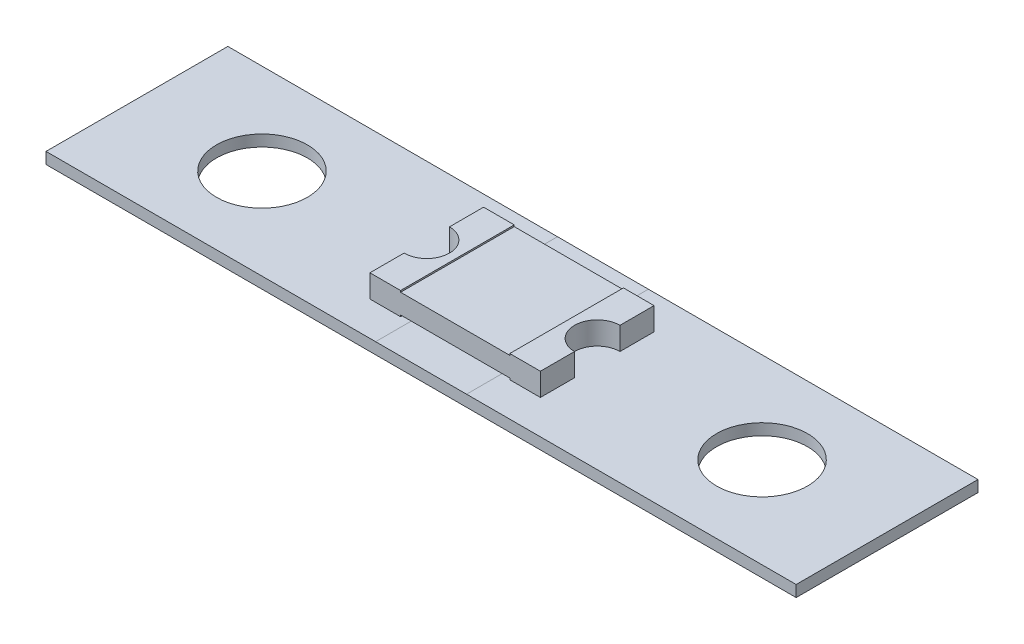
from build123d import *

# Parameters (mm, degrees)
SKETCH1_W           = 33
SKETCH1_H           = 8
SKETCH1_R           = 2
BOSS_EXTRUDE1_DEPTH = 0.5
BOSS_EXTRUDE2_DEPTH = 1
SKETCH4_W           = 4.803572116
SKETCH4_H           = 0.067925827
CUT_EXTRUDE1_DEPTH  = 7.5


with BuildPart() as part:
    # Sketch1 → Boss-Extrude1 (new body)
    with BuildSketch(Plane(origin=(0, 0, 0), x_dir=(1, 0, 0), z_dir=(0, 1, 0))):
        Rectangle(SKETCH1_W, SKETCH1_H)
        with Locations((-11, 0)):
            Circle(SKETCH1_R, mode=Mode.SUBTRACT)
        with Locations((11, 0)):
            Circle(SKETCH1_R, mode=Mode.SUBTRACT)
    extrude(amount=BOSS_EXTRUDE1_DEPTH)


with BuildPart() as body_2:
    # Sketch3 → Boss-Extrude2 (new body)
    with BuildSketch(Plane(origin=(0, 0.5, 0), x_dir=(1, 0, 0), z_dir=(0, 1, 0))):
        with BuildLine():
            Line((-3.75, -1), (-3.75, -2.5))
            Line((-3.75, -2.5), (3.75, -2.5))
            Line((3.75, -2.5), (3.75, -1))
            ThreePointArc((3.75, -1), (2.75, 0), (3.75, 1))
            Line((3.75, 1), (3.75, 2.5))
            Line((3.75, 2.5), (-3.75, 2.5))
            Line((-3.75, 2.5), (-3.75, 1))
            ThreePointArc((-3.75, 1), (-3.042893219, 0.707106781), (-2.75, 0))
            ThreePointArc((-2.75, 0), (-3.042893219, -0.707106781), (-3.75, -1))
        make_face()
    extrude(amount=BOSS_EXTRUDE2_DEPTH)

    # Sketch4 → Cut-Extrude1 (cut, through all)
    with BuildSketch(Plane.XY.offset(2.5)):
        with Locations((0, 1.466037087)):
            Rectangle(SKETCH4_W, SKETCH4_H)
        with Locations((0, 0.533962914)):
            Rectangle(SKETCH4_W, SKETCH4_H)
    extrude(amount=-CUT_EXTRUDE1_DEPTH, mode=Mode.SUBTRACT)


solid = Compound([part.part, body_2.part])
